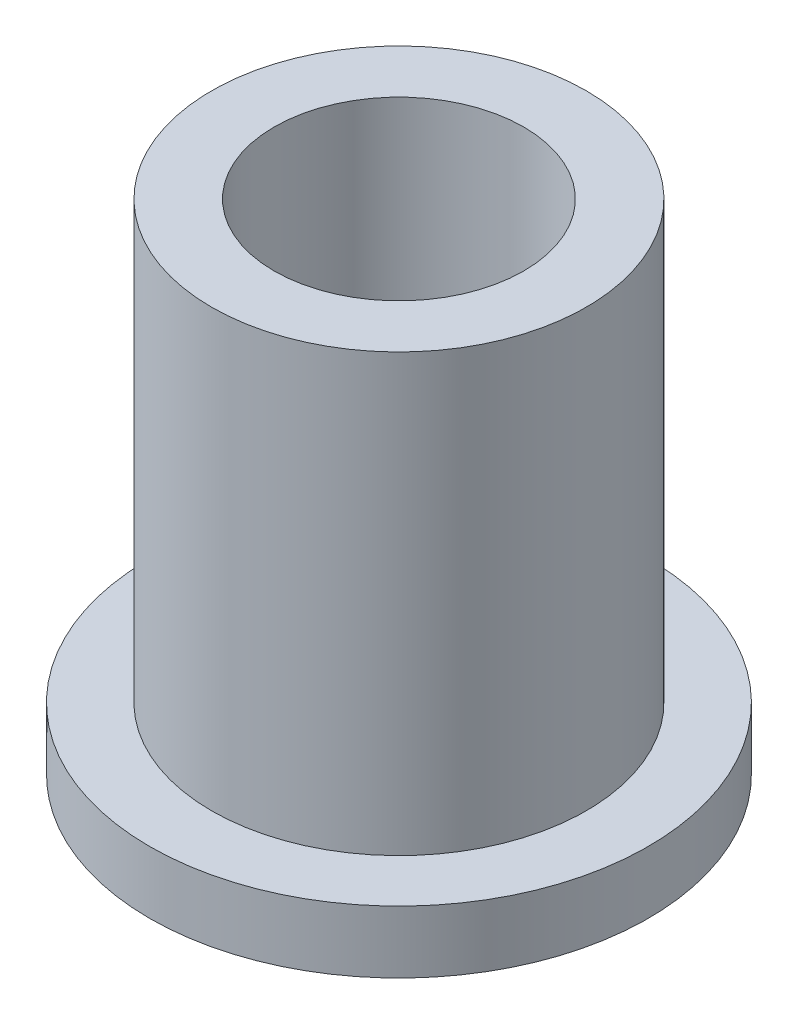
from build123d import *

# Parameters (mm, degrees)
SKETCH2_R           = 6.015
SKETCH2_R_2         = 4.005
BOSS_EXTRUDE1_DEPTH = 16
SKETCH3_R           = 8
SKETCH3_R_2         = 6.015
BOSS_EXTRUDE2_DEPTH = 2


with BuildPart() as part:
    # Sketch2 → Boss-Extrude1 (new body)
    with BuildSketch(Plane(origin=(0, 0, 0), x_dir=(1, 0, 0), z_dir=(0, 1, 0))):
        Circle(SKETCH2_R)
        Circle(SKETCH2_R_2, mode=Mode.SUBTRACT)
    extrude(amount=BOSS_EXTRUDE1_DEPTH)

    # Sketch3 → Boss-Extrude2 (add)
    with BuildSketch(Plane(origin=(0, 0, 0), x_dir=(1, 0, 0), z_dir=(0, 1, 0))):
        Circle(SKETCH3_R)
        Circle(SKETCH3_R_2, mode=Mode.SUBTRACT)
    extrude(amount=BOSS_EXTRUDE2_DEPTH)


solid = part.part
